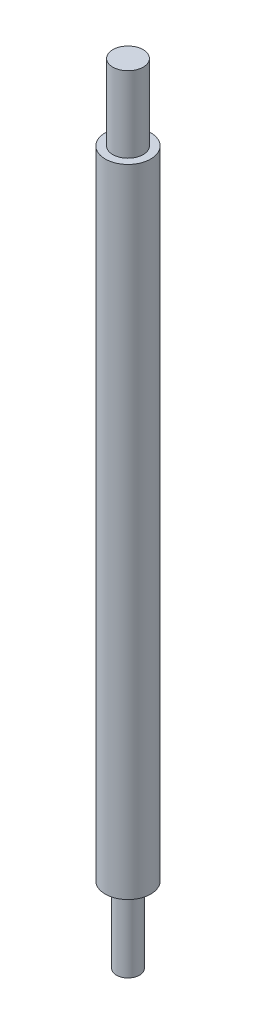
from build123d import *

# Parameters (mm, degrees)
SKETCH1_R           = 3
BOSS_EXTRUDE2_DEPTH = 84
SKETCH3_R           = 2
BOSS_EXTRUDE3_DEPTH = 10
SKETCH4_R           = 1.526030588
BOSS_EXTRUDE4_DEPTH = 10


with BuildPart() as part:
    # Sketch1 → Boss-Extrude2 (new body)
    with BuildSketch(Plane(origin=(0, 0, 0), x_dir=(1, 0, 0), z_dir=(0, 1, 0))):
        Circle(SKETCH1_R)
    extrude(amount=BOSS_EXTRUDE2_DEPTH)

    # Sketch3 → Boss-Extrude3 (add)
    with BuildSketch(Plane(origin=(0, 84, 0), x_dir=(1, 0, 0), z_dir=(0, 1, 0))):
        Circle(SKETCH3_R)
    extrude(amount=BOSS_EXTRUDE3_DEPTH)

    # Sketch4 → Boss-Extrude4 (add)
    with BuildSketch(Plane.XZ):
        Circle(SKETCH4_R)
    extrude(amount=BOSS_EXTRUDE4_DEPTH)


solid = part.part
